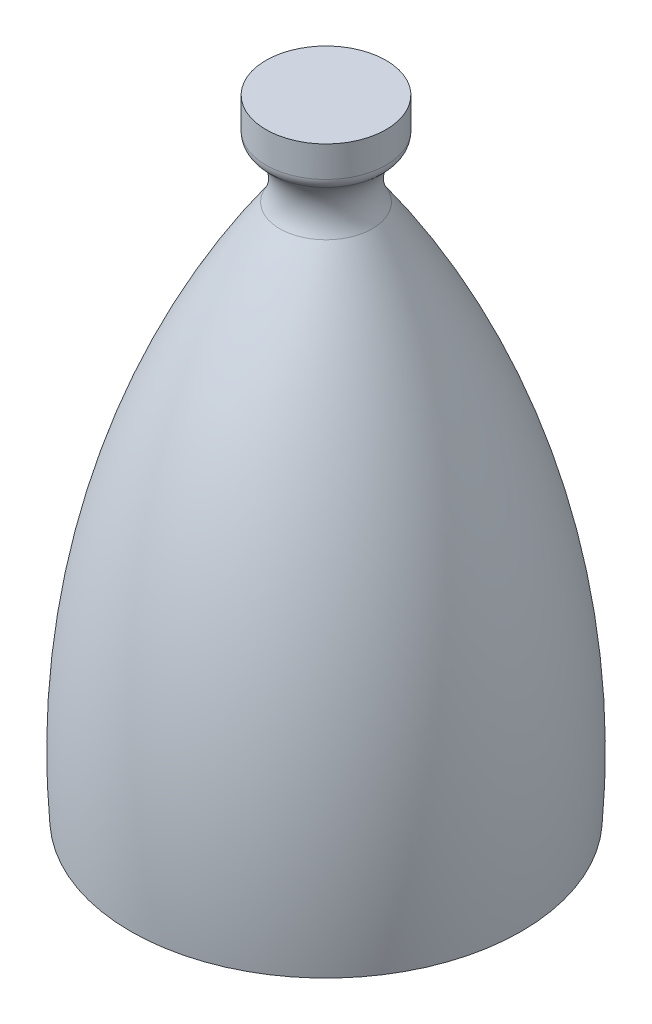
from build123d import *

# Parameters (mm, degrees)
SKETCH7_4_W = 44.471765842
SKETCH7_4_H = 27.926166375
FILLET1_R   = 10


with BuildPart() as part:
    # Sketch7 → Revolve1 (revolve)
    with BuildSketch(Plane.XY):
        with BuildLine():
            Line((71.702906323, 1000.353807812), (71.702906323, 564.083974187))
            Line((71.702906323, 564.083974187), (216.402906323, 564.083974187))
            ThreePointArc((216.402906323, 564.083974187), (195.597200889, 771.440280452), (105.982681142, 959.585843719))
            ThreePointArc((105.982681142, 959.585843719), (102.635354835, 982.08065622), (116.174672165, 1000.353807812))
            Line((116.174672165, 1000.353807812), (71.702906323, 1000.353807812))
        make_face()
    revolve(axis=Axis((71.702906323, 564.083974187, 0), (0, 1, 0)))

    # Sketch7_4 → Revolve2 (revolve)
    with BuildSketch(Plane.XY):
        with Locations((93.938789244, 1014.316891)):
            Rectangle(SKETCH7_4_W, SKETCH7_4_H)
    revolve(axis=Axis((71.702906323, 564.083974187, 0), (0, 1, 0)))

    # Fillet1
    fillet1_edges = [part.edges().sort_by_distance(p)[0] for p in [
        (27.231140482, 1000.353807812, 0),
    ]]
    fillet(fillet1_edges, radius=FILLET1_R)


solid = part.part
